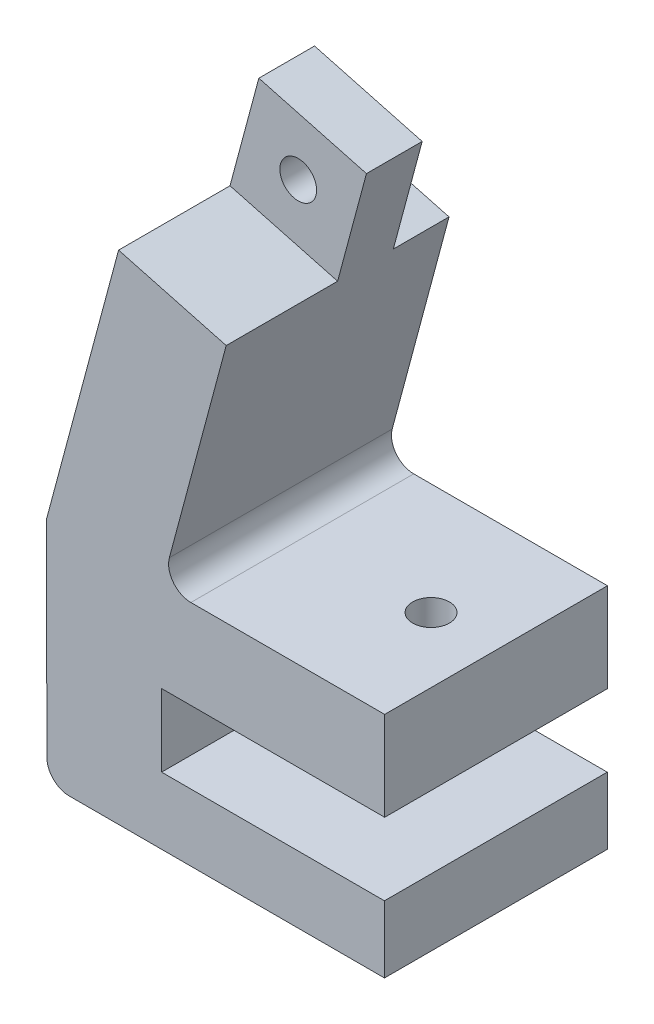
from build123d import *

# Parameters (mm, degrees)
EXTRUDE_1_DEPTH        = 20
FILLET_1_R             = 2
FILLET_2_R             = 2
SKETCH_30_W            = 1.65
SKETCH_30_H            = 8
SKETCH_31_R            = 3.5
CUT_EXTRUDE_1_DEPTH    = 4
CUT_EXTRUDE_2_DEPTH    = 10
SKETCH_34_R            = 3.25
CUT_EXTRUDE_3_DEPTH    = 6
HOLE_WIZARD_M4_2_D     = 3.3
HOLE_WIZARD_M4_2_DEPTH = 4
SKETCH_38_W            = 5
SKETCH_38_H            = 10
CUT_EXTRUDE_4_DEPTH    = 11


with BuildPart() as part:
    # 草图1 → 凸台-拉伸1 (new body)
    with BuildSketch(Plane.XY):
        Polygon((0.020144186, -0.052366179), (0.016918395, 5.947632954), (-19.983081605, 5.947632954), (-20.000068427, 12.447632954), (0.03759791, 12.447632954), (0.03759791, 20.447632954), (-19.96240209, 20.447632954), (-11.597239053, 51.666846423), (-21.256497316, 54.255036874), (-30.315163894, 20.447632954), (-30.279663837, -0.052366179), align=None)
    extrude(amount=EXTRUDE_1_DEPTH)

    # 圆角1
    fillet_1_edges = [part.edges().sort_by_distance(p)[0] for p in [
        (-19.96240209, 20.447632954, 10),
    ]]
    fillet(fillet_1_edges, radius=FILLET_1_R)

    # 圆角2
    fillet_2_edges = [part.edges().sort_by_distance(p)[0] for p in [
        (-30.279663837, -0.052366179, 10),
    ]]
    fillet(fillet_2_edges, radius=FILLET_2_R)

    # 草图30 → M4 螺纹孔的螺纹孔钻头1 (revolve, cut)
    with BuildSketch(Plane(origin=(-5.798619526, 12.447632954, 10), x_dir=(0, 0, -1), z_dir=(1, 0, 0))):
        with Locations((0.825, 4)):
            Rectangle(SKETCH_30_W, SKETCH_30_H)
    revolve(axis=Axis((-5.798619526, 6.097632954, 10), (0, 1, 0)), mode=Mode.SUBTRACT)

    # 草图31 → 切除-拉伸1 (cut)
    with BuildSketch(Plane.XZ.offset(-12.447632954)):
        with Locations((-5.798619526, 10)):
            Circle(SKETCH_31_R)
    extrude(amount=-CUT_EXTRUDE_1_DEPTH, mode=Mode.SUBTRACT)

    # 草图33 → 切除-拉伸2 (cut)
    with BuildSketch(Plane.XY.offset(20)):
        Polygon((-21.256497316, 54.255036874), (-11.597239053, 51.666846423), (-14.185429504, 42.00758816), (-23.844687767, 44.595778611), align=None)
    extrude(amount=-CUT_EXTRUDE_2_DEPTH, mode=Mode.SUBTRACT)

    # 草图34 → 切除-拉伸3 (cut)
    with BuildSketch(Plane(origin=(0, 0, 0), x_dir=(-1, 0, 0), z_dir=(0, 0, -1))):
        with Locations((17.72096341, 48.131312517)):
            Circle(SKETCH_34_R)
    extrude(amount=-CUT_EXTRUDE_3_DEPTH, mode=Mode.SUBTRACT)

    # M4 螺纹孔的螺纹孔钻头2
    with Locations(Plane(origin=(0, 0, 6), x_dir=(-1, 0, 0), z_dir=(0, 0, -1))):
        with Locations((17.72096341, 48.131312517)):
            Hole(HOLE_WIZARD_M4_2_D / 2, depth=HOLE_WIZARD_M4_2_DEPTH)

    # 草图38 → 切除-拉伸4 (cut)
    with BuildSketch(Plane(origin=(-23.737082949, 6.360332207, 0), x_dir=(0, 0, -1), z_dir=(0.965925826, -0.258819045, 0))):
        with Locations((-2.5, 41.904754985)):
            Rectangle(SKETCH_38_W, SKETCH_38_H)
    extrude(amount=-CUT_EXTRUDE_4_DEPTH, mode=Mode.SUBTRACT)


solid = part.part
